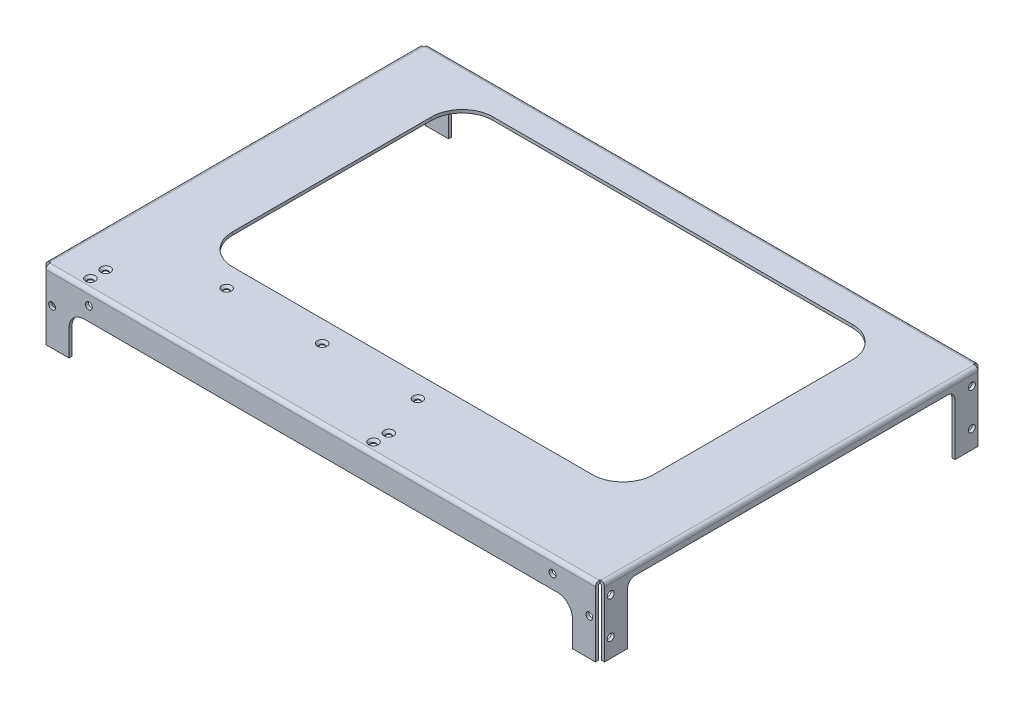
from build123d import *

# Parameters (mm, degrees)
BOSS_EXTRUDE1_DEPTH                             = 182.5
CUT_EXTRUDE1_DEPTH                              = 251
CUT_EXTRUDE2_DEPTH                              = 10
SKETCH4_W                                       = 2
SKETCH4_H                                       = 246
BOSS_EXTRUDE2_DEPTH                             = 43
SKETCH5_W                                       = 3
SKETCH5_H                                       = 3
CUT_EXTRUDE3_DEPTH                              = 46
FILLET1_R                                       = 0.5
FILLET2_R                                       = 2.5
CUT_EXTRUDE6_DEPTH                              = 366
SKETCH9_R                                       = 2.25
CUT_EXTRUDE7_DEPTH                              = 366
SKETCH10_R                                      = 2.25
CUT_EXTRUDE8_DEPTH                              = 10
SKETCH11_R                                      = 2.25
CUT_EXTRUDE9_DEPTH                              = 10
SKETCH12_R                                      = 1.5
CUT_EXTRUDE10_DEPTH                             = 10
CSK_FOR_M3_FLAT_HEAD_MACHINE_SCREW1_D           = 3.4
CSK_FOR_M3_FLAT_HEAD_MACHINE_SCREW1_CSINK_D     = 6.3
CSK_FOR_M3_FLAT_HEAD_MACHINE_SCREW1_CSINK_ANGLE = 90


with BuildPart() as part:
    # Sketch1 → Boss-Extrude1 (new body, symmetric)
    with BuildSketch(Plane(origin=(0, 0, 0), x_dir=(0, 0, -1), z_dir=(1, 0, 0))):
        with BuildLine():
            Line((123, -45), (125, -45))
            Line((125, -45), (125, -2.5))
            ThreePointArc((125, -2.5), (124.267766953, -0.732233047), (122.5, 0))
            Line((122.5, 0), (-122.5, 0))
            ThreePointArc((-122.5, 0), (-124.267766953, -0.732233047), (-125, -2.5))
            Line((-125, -2.5), (-125, -45))
            Line((-125, -45), (-123, -45))
            Line((-123, -45), (-123, -2.5))
            ThreePointArc((-123, -2.5), (-122.853553391, -2.146446609), (-122.5, -2))
            Line((-122.5, -2), (122.5, -2))
            ThreePointArc((122.5, -2), (122.853553391, -2.146446609), (123, -2.5))
            Line((123, -2.5), (123, -45))
        make_face()
    extrude(amount=BOSS_EXTRUDE1_DEPTH, both=True)

    # Sketch2 → Cut-Extrude1 (cut, through all)
    with BuildSketch(Plane.XY.offset(125)):
        with BuildLine():
            Line((-164.5, -45), (164.5, -45))
            Line((164.5, -45), (164.5, -28))
            ThreePointArc((164.5, -28), (161.571067812, -20.928932188), (154.5, -18))
            Line((154.5, -18), (-154.5, -18))
            ThreePointArc((-154.5, -18), (-161.571067812, -20.928932188), (-164.5, -28))
            Line((-164.5, -28), (-164.5, -45))
        make_face()
    extrude(amount=-CUT_EXTRUDE1_DEPTH, mode=Mode.SUBTRACT)

    # Sketch3 → Cut-Extrude2 (cut)
    with BuildSketch(Plane(origin=(0, 0, 0), x_dir=(1, 0, 0), z_dir=(0, 1, 0))):
        with BuildLine():
            Line((-117.5, 105), (117.5, 105))
            ThreePointArc((117.5, 105), (131.642135624, 99.142135624), (137.5, 85))
            Line((137.5, 85), (137.5, -45))
            ThreePointArc((137.5, -45), (131.642135624, -59.142135624), (117.5, -65))
            Line((117.5, -65), (-117.5, -65))
            ThreePointArc((-117.5, -65), (-131.642135624, -59.142135624), (-137.5, -45))
            Line((-137.5, -45), (-137.5, 85))
            ThreePointArc((-137.5, 85), (-131.642135624, 99.142135624), (-117.5, 105))
        make_face()
    extrude(amount=-CUT_EXTRUDE2_DEPTH, mode=Mode.SUBTRACT)

    # Sketch4 → Boss-Extrude2 (add)
    with BuildSketch(Plane.XZ.offset(2)):
        with Locations((-181.5, 0)):
            Rectangle(SKETCH4_W, SKETCH4_H)
        with Locations((181.5, 0)):
            Rectangle(SKETCH4_W, SKETCH4_H)
    extrude(amount=BOSS_EXTRUDE2_DEPTH)

    # Sketch5 → Cut-Extrude3 (cut, through all)
    with BuildSketch(Plane.XZ.offset(45)):
        with Locations((-181, 123.5)):
            Rectangle(SKETCH5_W, SKETCH5_H)
        with Locations((-181, -123.5)):
            Rectangle(SKETCH5_W, SKETCH5_H)
        with Locations((181, -123.5)):
            Rectangle(SKETCH5_W, SKETCH5_H)
        with Locations((181, 123.5)):
            Rectangle(SKETCH5_W, SKETCH5_H)
    extrude(amount=-CUT_EXTRUDE3_DEPTH, mode=Mode.SUBTRACT)

    # Fillet1
    fillet1_edges = [part.edges().sort_by_distance(p)[0] for p in [
        (-180.5, -2, 0),
        (180.5, -2, 0),
    ]]
    fillet(fillet1_edges, radius=FILLET1_R)

    # Fillet2
    fillet2_edges = [part.edges().sort_by_distance(p)[0] for p in [
        (-182.5, 0, 0),
        (182.5, 0, 0),
    ]]
    fillet(fillet2_edges, radius=FILLET2_R)

    # Sketch8 → Cut-Extrude6 (cut, through all)
    with BuildSketch(Plane.ZY.offset(182.5)):
        with BuildLine():
            Line((-107, -45), (107, -45))
            Line((107, -45), (107, -11))
            ThreePointArc((107, -11), (105.535533906, -7.464466094), (102, -6))
            Line((102, -6), (-102, -6))
            ThreePointArc((-102, -6), (-105.535533906, -7.464466094), (-107, -11))
            Line((-107, -11), (-107, -45))
        make_face()
    extrude(amount=-CUT_EXTRUDE6_DEPTH, mode=Mode.SUBTRACT)

    # Sketch9 → Cut-Extrude7 (cut, through all)
    with BuildSketch(Plane.ZY.offset(182.5)):
        with Locations((-118, -9)):
            Circle(SKETCH9_R)
        with Locations((-118, -33)):
            Circle(SKETCH9_R)
        with Locations((118, -9)):
            Circle(SKETCH9_R)
        with Locations((118, -33)):
            Circle(SKETCH9_R)
    extrude(amount=-CUT_EXTRUDE7_DEPTH, mode=Mode.SUBTRACT)

    # Sketch10 → Cut-Extrude8 (cut)
    with BuildSketch(Plane.XY.offset(125)):
        with Locations((-151.5, -9)):
            Circle(SKETCH10_R)
        with Locations((175.5, -21)):
            Circle(SKETCH10_R)
        with Locations((151.5, -9)):
            Circle(SKETCH10_R)
        with Locations((-175.5, -21)):
            Circle(SKETCH10_R)
    extrude(amount=-CUT_EXTRUDE8_DEPTH, mode=Mode.SUBTRACT)

    # Sketch11 → Cut-Extrude9 (cut)
    with BuildSketch(Plane(origin=(0, 0, -125), x_dir=(-1, 0, 0), z_dir=(0, 0, -1))):
        with Locations(Location((-175.5, -21, 0), (0, 0, 180))):  # turned: the seam where the file's is
            Circle(SKETCH11_R)
        with Locations(Location((-151.5, -9, 0), (0, 0, 180))):  # turned: the seam where the file's is
            Circle(SKETCH11_R)
        with Locations(Location((151.5, -9, 0), (0, 0, 180))):  # turned: the seam where the file's is
            Circle(SKETCH11_R)
        with Locations(Location((175.5, -21, 0), (0, 0, 180))):  # turned: the seam where the file's is
            Circle(SKETCH11_R)
    extrude(amount=-CUT_EXTRUDE9_DEPTH, mode=Mode.SUBTRACT)

    # Sketch12 → Cut-Extrude10 (cut)
    with BuildSketch(Plane(origin=(0, 0, 0), x_dir=(1, 0, 0), z_dir=(0, 1, 0))):
        with Locations(Location((-45, -79, 0), (0, 0, 270))):  # turned: the seam where the file's is
            Circle(SKETCH12_R)
        with Locations(Location((17.5, -79, 0), (0, 0, 270))):  # turned: the seam where the file's is
            Circle(SKETCH12_R)
        with Locations(Location((-107.5, -79, 0), (0, 0, 270))):  # turned: the seam where the file's is
            Circle(SKETCH12_R)
        with Locations(Location((-157.5, -108, 0), (0, 0, 270))):  # turned: the seam where the file's is
            Circle(SKETCH12_R)
        with Locations(Location((-157.5, -118, 0), (0, 0, 270))):  # turned: the seam where the file's is
            Circle(SKETCH12_R)
        with Locations(Location((27.5, -108, 0), (0, 0, 270))):  # turned: the seam where the file's is
            Circle(SKETCH12_R)
        with Locations(Location((27.5, -118, 0), (0, 0, 270))):  # turned: the seam where the file's is
            Circle(SKETCH12_R)
    extrude(amount=-CUT_EXTRUDE10_DEPTH, mode=Mode.SUBTRACT)

    # CSK for M3 Flat Head Machine Screw1 (through all)
    with Locations(Plane(origin=(0, 0, 0), x_dir=(-1, 0, 0), z_dir=(0, 1, 0))):
        with Locations((107.5, 79), (45, 79), (-17.5, 79), (157.5, 108), (157.5, 118), (-27.5, 108), (-27.5, 118)):
            CounterSinkHole(CSK_FOR_M3_FLAT_HEAD_MACHINE_SCREW1_D / 2, CSK_FOR_M3_FLAT_HEAD_MACHINE_SCREW1_CSINK_D / 2, counter_sink_angle=CSK_FOR_M3_FLAT_HEAD_MACHINE_SCREW1_CSINK_ANGLE)


solid = part.part
